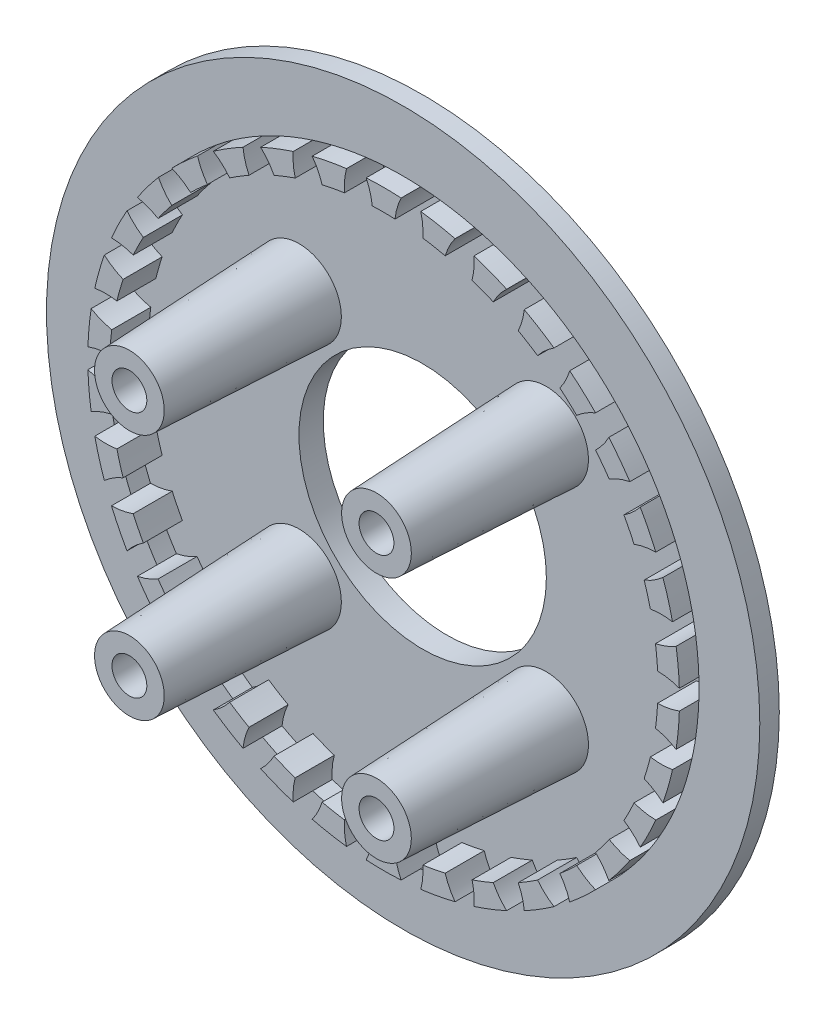
from build123d import *

# Parameters (mm, degrees)
SKETCH2_R           = 54.85
BOSS_EXTRUDE1_DEPTH = 3
SKETCH3_R           = 47.005
BOSS_EXTRUDE2_DEPTH = 3.74
SKETCH4_R           = 19.025
CUT_EXTRUDE1_DEPTH  = 7.74
SKETCH5_R           = 45.5
CUT_EXTRUDE2_DEPTH  = 3
SKETCH6_R           = 6.5
BOSS_EXTRUDE3_DEPTH = 26.1
BOSS_EXTRUDE3_TAPER = 2.5
SKETCH10_R          = 2.68034669
CUT_EXTRUDE3_DEPTH  = 30.84
CIRPATTERN1_COUNT   = 4
BOSS_EXTRUDE7_DEPTH = 6
CIRPATTERN3_COUNT   = 34


with BuildPart() as part:
    # Sketch2 → Boss-Extrude1 (new body)
    with BuildSketch(Plane.XY):
        Circle(SKETCH2_R)
    extrude(amount=BOSS_EXTRUDE1_DEPTH)

    # Sketch3 → Boss-Extrude2 (add)
    with BuildSketch(Plane(origin=(0, 0, 0), x_dir=(-1, 0, 0), z_dir=(0, 0, -1))):
        Circle(SKETCH3_R)
    extrude(amount=BOSS_EXTRUDE2_DEPTH)

    # Sketch4 → Cut-Extrude1 (cut, through all)
    with BuildSketch(Plane.XY.offset(3)):
        Circle(SKETCH4_R)
    extrude(amount=-CUT_EXTRUDE1_DEPTH, mode=Mode.SUBTRACT)

    # Sketch5 → Cut-Extrude2 (cut)
    with BuildSketch(Plane.XY.offset(3)):
        Circle(SKETCH5_R)
    extrude(amount=-CUT_EXTRUDE2_DEPTH, mode=Mode.SUBTRACT)

    # Sketch6 → Boss-Extrude3 (add)
    with BuildSketch(Plane.XY):
        with Locations((-19, 19)):
            Circle(SKETCH6_R)
        with Locations((19, 19)):
            Circle(SKETCH6_R)
        with Locations((-19, -19)):
            Circle(SKETCH6_R)
        with Locations((19, -19)):
            Circle(SKETCH6_R)
    extrude(amount=BOSS_EXTRUDE3_DEPTH, taper=BOSS_EXTRUDE3_TAPER)

    # Sketch10 → Cut-Extrude3 (cut, through all)
    with BuildSketch(Plane.XY.offset(26.1)):
        with Locations((19, -19)):
            Circle(SKETCH10_R)
    cut_extrude3 = extrude(amount=-CUT_EXTRUDE3_DEPTH, mode=Mode.SUBTRACT)

    # CirPattern1: Cut-Extrude3 ×4 about axis
    cirpattern1_axis = Axis((0, 0, 0), (0, 0, 1))
    for i in range(1, CIRPATTERN1_COUNT):
        add(cut_extrude3.rotate(cirpattern1_axis, i * 360 / CIRPATTERN1_COUNT), mode=Mode.SUBTRACT)

    # Sketch17 → Boss-Extrude7 (add)
    with BuildSketch(Plane.XY):
        with BuildLine():
            ThreePointArc((-2.685, 45.420708658), (-2.077294419, 43.824761871), (-1.75, 42.148685923))
            ThreePointArc((-1.75, 42.148685923), (0, 42.185), (1.75, 42.148685923))
            ThreePointArc((1.75, 42.148685923), (2.077294419, 43.824761871), (2.685, 45.420708658))
            ThreePointArc((2.685, 45.420708658), (0, 45.5), (-2.685, 45.420708658))
        make_face()
    boss_extrude7 = extrude(amount=BOSS_EXTRUDE7_DEPTH)

    # CirPattern3: Boss-Extrude7 ×34 about axis
    cirpattern3_axis = Axis((0, 0, 0), (0, 0, 1))
    for i in range(1, CIRPATTERN3_COUNT):
        add(boss_extrude7.rotate(cirpattern3_axis, i * 360 / CIRPATTERN3_COUNT))


solid = part.part
